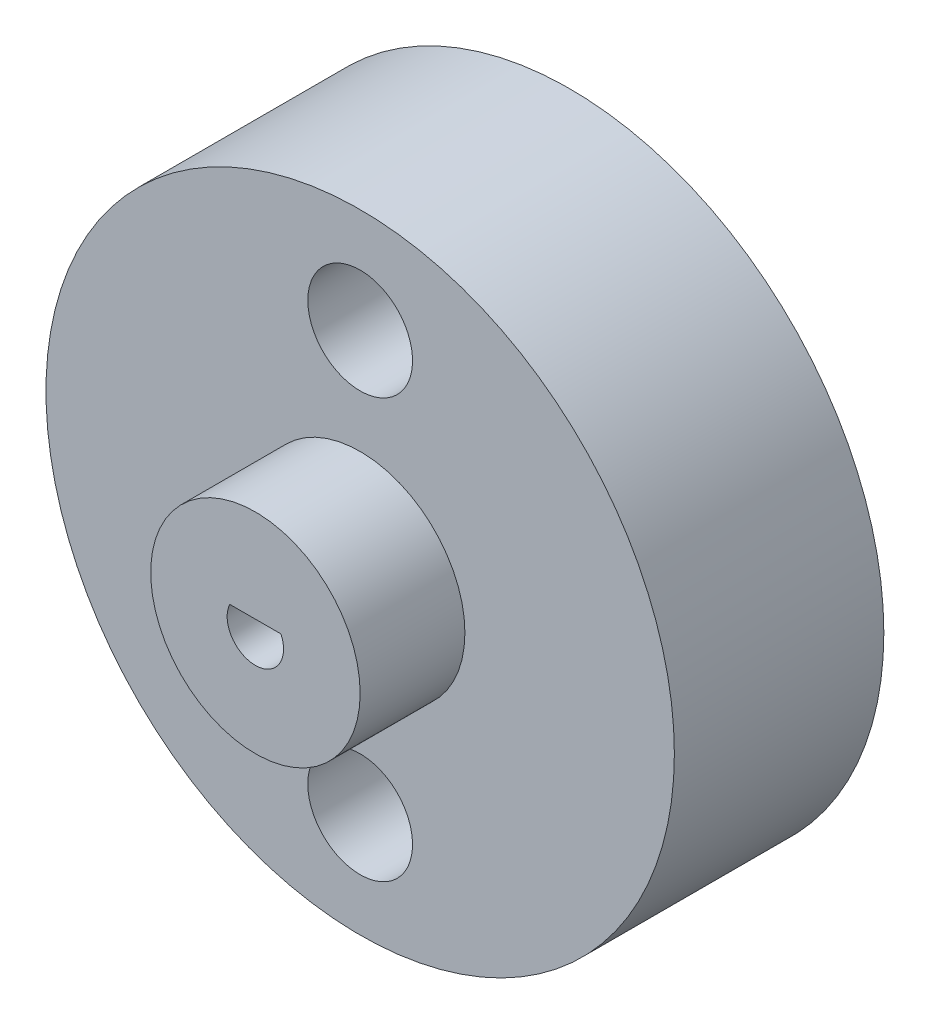
from build123d import *

# Parameters (mm, degrees)
SKETCH1_R               = 19.05
BOSS_EXTRUDE1_DEPTH     = 12.7
SKETCH4_R               = 3.175
CUT_EXTRUDE2_DEPTH      = 13.7
CUT_EXTRUDE4_DEPTH      = 1
CUT_EXTRUDE4_DEPTH_BACK = 13.7
SKETCH7_R               = 6.35
BOSS_EXTRUDE2_DEPTH     = 6.35
CUT_EXTRUDE5_DEPTH      = 20.05


with BuildPart() as part:
    # Sketch1 → Boss-Extrude1 (new body)
    with BuildSketch(Plane.XY):
        Circle(SKETCH1_R)
    extrude(amount=BOSS_EXTRUDE1_DEPTH)

    # Sketch4 → Cut-Extrude2 (cut, through all)
    with BuildSketch(Plane(origin=(0, 0, 0), x_dir=(-1, 0, 0), z_dir=(0, 0, -1))):
        with Locations((0, 12.7)):
            Circle(SKETCH4_R)
        with Locations((0, -12.7)):
            Circle(SKETCH4_R)
    extrude(amount=-CUT_EXTRUDE2_DEPTH, mode=Mode.SUBTRACT)

    # Sketch6 → Cut-Extrude4 (cut, two sides)
    with BuildSketch(Plane.XY.offset(12.7)) as cut_extrude4_sk:
        with BuildLine():
            Line((1.546311471, 0.716838774), (0, 0.716838774))
            Line((0, 0.716838774), (-1.557372698, 0.716838774))
            ThreePointArc((-1.557372698, 0.716838774), (-0.005530614, -1.711645493), (1.546311471, 0.716838774))
        make_face()
    extrude(amount=CUT_EXTRUDE4_DEPTH, mode=Mode.SUBTRACT)
    extrude(cut_extrude4_sk.sketch, amount=-CUT_EXTRUDE4_DEPTH_BACK, mode=Mode.SUBTRACT)

    # Sketch7 → Boss-Extrude2 (add)
    with BuildSketch(Plane.XY.offset(12.7)):
        Circle(SKETCH7_R)
    extrude(amount=BOSS_EXTRUDE2_DEPTH)

    # Sketch8 → Cut-Extrude5 (cut, through all)
    with BuildSketch(Plane(origin=(0, 0, 0), x_dir=(-1, 0, 0), z_dir=(0, 0, -1))):
        with BuildLine():
            Line((-1.546311471, 0.716838774), (1.557372698, 0.716838774))
            ThreePointArc((1.557372698, 0.716838774), (0.005530614, -1.711645493), (-1.546311471, 0.716838774))
        make_face()
    extrude(amount=-CUT_EXTRUDE5_DEPTH, mode=Mode.SUBTRACT)


solid = part.part
